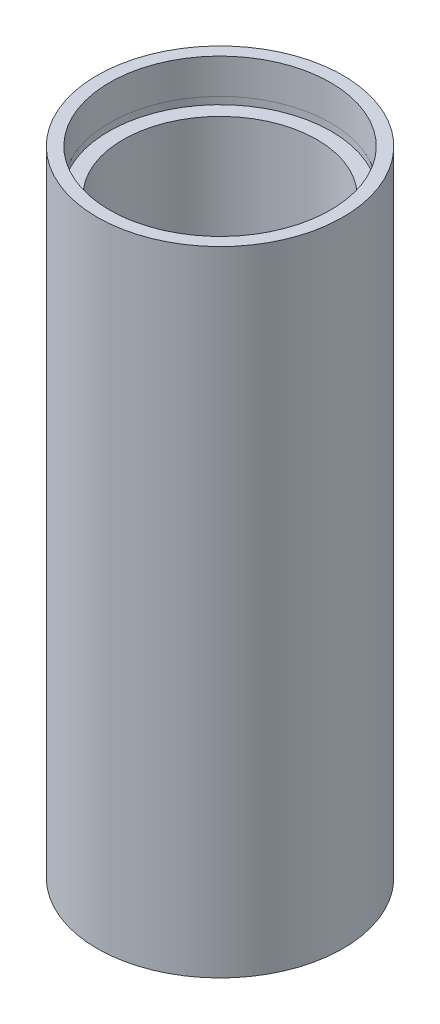
from build123d import *


with BuildPart() as part:
    # 草图1 → 旋转1 (revolve)
    with BuildSketch(Plane.XY, mode=Mode.PRIVATE) as revolve_1_sk:
        Polygon((13.75, 0), (13.75, 4.5), (14.35, 4.5), (14.35, 5.5), (12.5, 5.5), (12.5, 76.2), (14.35, 76.2), (14.35, 77.2), (14.25, 77.2), (14.25, 81.7), (15.85, 81.7), (15.85, 0), align=None)
    revolve(revolve_1_sk.sketch.rotate(Axis((0, 161.376166943, 0), (0, -1, 0)), 90), axis=Axis((0, 161.376166943, 0), (0, -1, 0)))  # turned: the seam where the file's is


solid = part.part
